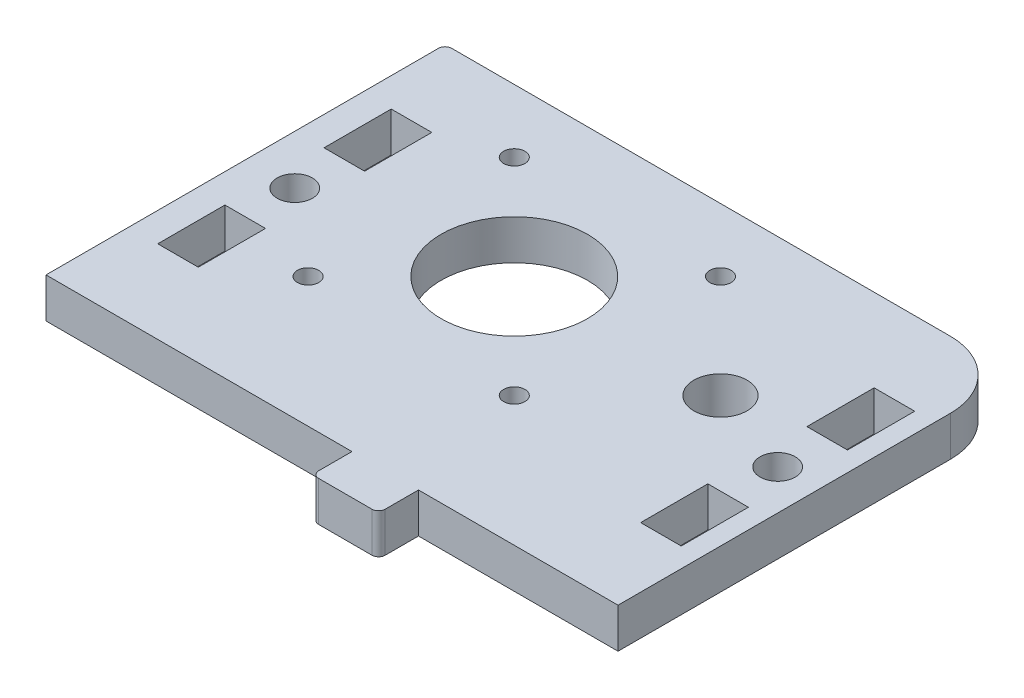
from build123d import *

# Parameters (mm, degrees)
SKETCH1_W                = 86
SKETCH1_H                = 60
BOSS_EXTRUDE1_DEPTH      = 6
M5_CLEARANCE_HOLE1_D     = 5.3
FILLET1_R                = 10
M5_CLEARANCE_HOLE2_D     = 5.3
F_8_0_8_DIAMETER_HOLE1_D = 8
M3_CLEARANCE_HOLE1_D     = 3.2
SKETCH6_R                = 11
CUT_EXTRUDE3_DEPTH       = 7
FILLET1343_R             = 1
SKETCH73_W               = 6.1
SKETCH73_H               = 10.1
CUT_EXTRUDE24_DEPTH      = 4
CUT_EXTRUDE24_DEPTH_BACK = 4
SKETCH74_W               = 6.1
SKETCH74_H               = 10.1
CUT_EXTRUDE25_DEPTH      = 4
CUT_EXTRUDE25_DEPTH_BACK = 4
SKETCH2349_W             = 10
SKETCH2349_H             = 6
BOSS_EXTRUDE2347_DEPTH   = 6
FILLET1346_R             = 1


with BuildPart() as part:
    # Sketch1 → Boss-Extrude1 (new body)
    with BuildSketch(Plane(origin=(0, 0, 0), x_dir=(1, 0, 0), z_dir=(0, 1, 0))):
        Rectangle(SKETCH1_W, SKETCH1_H)
    extrude(amount=BOSS_EXTRUDE1_DEPTH)

    # M5 Clearance Hole1 (through all)
    with Locations(Plane(origin=(0, 6, 0), x_dir=(1, 0, 0), z_dir=(0, 1, 0))):
        with Locations((-35.6, 0)):
            Hole(M5_CLEARANCE_HOLE1_D / 2)

    # Fillet1
    fillet1_edges = [part.edges().sort_by_distance(p)[0] for p in [
        (43, 3, -30),
    ]]
    fillet(fillet1_edges, radius=FILLET1_R)

    # M5 Clearance Hole2 (through all)
    with Locations(Plane(origin=(0, 6, 0), x_dir=(1, 0, 0), z_dir=(0, 1, 0))):
        with Locations((37, 0)):
            Hole(M5_CLEARANCE_HOLE2_D / 2)

    # 8.0 _8_ Diameter Hole1 (through all)
    with Locations(Plane(origin=(0, 6, 0), x_dir=(1, 0, 0), z_dir=(0, 1, 0))):
        with Locations((23.4, 5)):
            Hole(F_8_0_8_DIAMETER_HOLE1_D / 2)

    # M3 Clearance Hole1 (through all)
    with Locations(Plane(origin=(-7.6, 0, -5), x_dir=(1, 0, 0), z_dir=(0, -1, 0))):
        with Locations((15.5, -15.5), (-15.5, -15.5), (-15.5, 15.5), (15.5, 15.5)):
            Hole(M3_CLEARANCE_HOLE1_D / 2)

    # Sketch6 → Cut-Extrude3 (cut, through all)
    with BuildSketch(Plane(origin=(-7.6, 0, -5), x_dir=(-1, 0, 0), z_dir=(0, -1, 0))):
        Circle(SKETCH6_R)
    extrude(amount=-CUT_EXTRUDE3_DEPTH, mode=Mode.SUBTRACT)

    # Fillet1343
    fillet1343_edges = [part.edges().sort_by_distance(p)[0] for p in [
        (-43, 3, -30),
    ]]
    fillet(fillet1343_edges, radius=FILLET1343_R)

    # Sketch73 → Cut-Extrude24 (cut, two sides)
    with BuildSketch(Plane(origin=(8.4, 3, -20), x_dir=(-1, 0, 0), z_dir=(0, -1, 0))) as cut_extrude24_sk:
        with Locations((44, -32.5)):
            Rectangle(SKETCH73_W, SKETCH73_H)
        with Locations((44, -7.5)):
            Rectangle(SKETCH73_W, SKETCH73_H)
    extrude(amount=CUT_EXTRUDE24_DEPTH, mode=Mode.SUBTRACT)
    extrude(cut_extrude24_sk.sketch, amount=-CUT_EXTRUDE24_DEPTH_BACK, mode=Mode.SUBTRACT)

    # Sketch74 → Cut-Extrude25 (cut, two sides)
    with BuildSketch(Plane(origin=(-7, 3, 20), x_dir=(1, 0, 0), z_dir=(0, -1, 0))) as cut_extrude25_sk:
        with Locations((44, -32.5)):
            Rectangle(SKETCH74_W, SKETCH74_H)
        with Locations((44, -7.5)):
            Rectangle(SKETCH74_W, SKETCH74_H)
    extrude(amount=CUT_EXTRUDE25_DEPTH, mode=Mode.SUBTRACT)
    extrude(cut_extrude25_sk.sketch, amount=-CUT_EXTRUDE25_DEPTH_BACK, mode=Mode.SUBTRACT)

    # Sketch2349 → Boss-Extrude2347 (add)
    with BuildSketch(Plane(origin=(8.767778608, 6, 30), x_dir=(-1, 0, 0), z_dir=(0, 0, 1))):
        with Locations((0.767778608, 3)):
            Rectangle(SKETCH2349_W, SKETCH2349_H)
    extrude(amount=BOSS_EXTRUDE2347_DEPTH)

    # Fillet1346
    fillet1346_edges = [part.edges().sort_by_distance(p)[0] for p in [
        (13, 3, 36),
        (3, 3, 36),
    ]]
    fillet(fillet1346_edges, radius=FILLET1346_R)


solid = part.part
